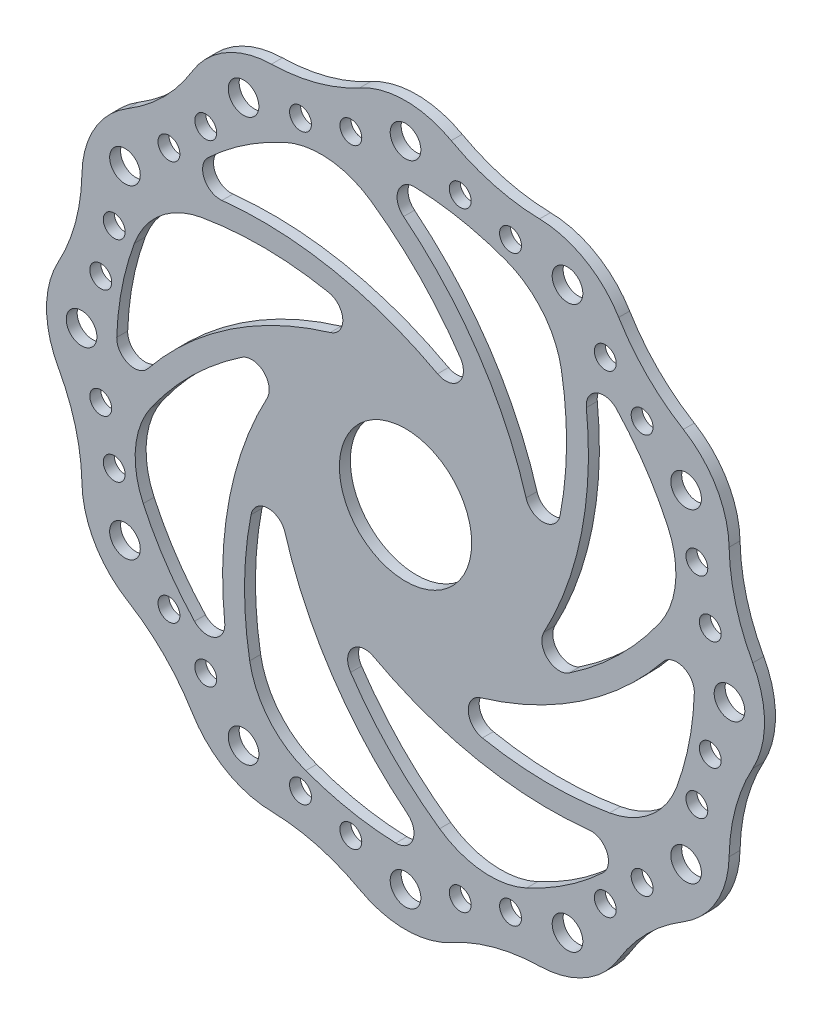
from build123d import *

# Parameters (mm, degrees)
SKETCH1_R           = 3.5
SKETCH1_R_2         = 2.5
BOSS_EXTRUDE1_DEPTH = 2.5
SKETCH2_R           = 15.109152198
CUT_EXTRUDE1_DEPTH  = 5


with BuildPart() as part:
    # Sketch1 → Boss-Extrude1 (new body)
    with BuildSketch(Plane.XY):
        with BuildLine():
            ThreePointArc((3625.909665863, 499.953549868), (3625.227827051, 505.34436193), (3623.225254773, 510.395645245))
            ThreePointArc((3623.225254773, 510.395645245), (3620.967241243, 515.156207087), (3619.298998646, 520.154060705))
            ThreePointArc((3619.298998646, 520.154060705), (3618.244812306, 525.316450201), (3617.820028464, 530.568224457))
            ThreePointArc((3617.820028464, 530.568224457), (3617.028665272, 535.944050269), (3614.923748973, 540.953549868))
            ThreePointArc((3614.923748973, 540.953549868), (3611.63785321, 545.281210655), (3607.377933086, 548.654464189))
            ThreePointArc((3607.377933086, 548.654464189), (3603.042155087, 551.648224915), (3599.098487809, 555.142371814))
            ThreePointArc((3599.098487809, 555.142371814), (3595.60434091, 559.086039091), (3592.610580184, 563.421817091))
            ThreePointArc((3592.610580184, 563.421817091), (3589.23732665, 567.681737215), (3584.909665863, 570.967632978))
            ThreePointArc((3584.909665863, 570.967632978), (3579.900166264, 573.072549277), (3574.524340452, 573.863912469))
            ThreePointArc((3574.524340452, 573.863912469), (3569.272566196, 574.288696311), (3564.1101767, 575.342882651))
            ThreePointArc((3564.1101767, 575.342882651), (3559.112323082, 577.011125248), (3554.35176124, 579.269138778))
            ThreePointArc((3554.35176124, 579.269138778), (3549.300477925, 581.271711056), (3543.909665863, 581.953549868))
            ThreePointArc((3543.909665863, 581.953549868), (3538.5188538, 581.271711056), (3533.467570485, 579.269138778))
            ThreePointArc((3533.467570485, 579.269138778), (3528.707008644, 577.011125248), (3523.709155026, 575.342882651))
            ThreePointArc((3523.709155026, 575.342882651), (3518.54676553, 574.288696311), (3513.294991274, 573.863912469))
            ThreePointArc((3513.294991274, 573.863912469), (3507.919165462, 573.072549277), (3502.909665863, 570.967632978))
            ThreePointArc((3502.909665863, 570.967632978), (3498.582005075, 567.681737215), (3495.208751542, 563.421817091))
            ThreePointArc((3495.208751542, 563.421817091), (3492.214990816, 559.086039091), (3488.720843917, 555.142371814))
            ThreePointArc((3488.720843917, 555.142371814), (3484.777176639, 551.648224915), (3480.44139864, 548.654464189))
            ThreePointArc((3480.44139864, 548.654464189), (3476.181478516, 545.281210655), (3472.895582753, 540.953549868))
            ThreePointArc((3472.895582753, 540.953549868), (3470.790666453, 535.944050269), (3469.999303262, 530.568224457))
            ThreePointArc((3469.999303262, 530.568224457), (3469.57451942, 525.316450201), (3468.520333079, 520.154060705))
            ThreePointArc((3468.520333079, 520.154060705), (3466.852090483, 515.156207087), (3464.594076953, 510.395645245))
            ThreePointArc((3464.594076953, 510.395645245), (3462.591504675, 505.34436193), (3461.909665863, 499.953549868))
            ThreePointArc((3461.909665863, 499.953549868), (3462.591504675, 494.562737805), (3464.594076953, 489.51145449))
            ThreePointArc((3464.594076953, 489.51145449), (3466.852090483, 484.750892649), (3468.520333079, 479.753039031))
            ThreePointArc((3468.520333079, 479.753039031), (3469.57451942, 474.590649535), (3469.999303262, 469.338875279))
            ThreePointArc((3469.999303262, 469.338875279), (3470.790666453, 463.963049467), (3472.895582753, 458.953549868))
            ThreePointArc((3472.895582753, 458.953549868), (3476.181478516, 454.62588908), (3480.44139864, 451.252635547))
            ThreePointArc((3480.44139864, 451.252635547), (3484.777176639, 448.258874821), (3488.720843917, 444.764727922))
            ThreePointArc((3488.720843917, 444.764727922), (3492.214990816, 440.821060644), (3495.208751542, 436.485282645))
            ThreePointArc((3495.208751542, 436.485282645), (3498.582005075, 432.225362521), (3502.909665863, 428.939466758))
            ThreePointArc((3502.909665863, 428.939466758), (3507.919165462, 426.834550458), (3513.294991274, 426.043187267))
            ThreePointArc((3513.294991274, 426.043187267), (3518.54676553, 425.618403425), (3523.709155026, 424.564217084))
            ThreePointArc((3523.709155026, 424.564217084), (3528.707008644, 422.895974488), (3533.467570485, 420.637960958))
            ThreePointArc((3533.467570485, 420.637960958), (3538.5188538, 418.63538868), (3543.909665863, 417.953549868))
            ThreePointArc((3543.909665863, 417.953549868), (3549.300477925, 418.63538868), (3554.35176124, 420.637960958))
            ThreePointArc((3554.35176124, 420.637960958), (3559.112323082, 422.895974488), (3564.1101767, 424.564217084))
            ThreePointArc((3564.1101767, 424.564217084), (3569.272566196, 425.618403425), (3574.524340452, 426.043187267))
            ThreePointArc((3574.524340452, 426.043187267), (3579.900166264, 426.834550458), (3584.909665863, 428.939466758))
            ThreePointArc((3584.909665863, 428.939466758), (3589.23732665, 432.225362521), (3592.610580184, 436.485282645))
            ThreePointArc((3592.610580184, 436.485282645), (3595.60434091, 440.821060644), (3599.098487809, 444.764727922))
            ThreePointArc((3599.098487809, 444.764727922), (3603.042155087, 448.258874821), (3607.377933086, 451.252635547))
            ThreePointArc((3607.377933086, 451.252635547), (3611.63785321, 454.62588908), (3614.923748973, 458.953549868))
            ThreePointArc((3614.923748973, 458.953549868), (3617.028665272, 463.963049467), (3617.820028464, 469.338875279))
            ThreePointArc((3617.820028464, 469.338875279), (3618.244812306, 474.590649535), (3619.298998646, 479.753039031))
            ThreePointArc((3619.298998646, 479.753039031), (3620.967241243, 484.750892649), (3623.225254773, 489.51145449))
            ThreePointArc((3623.225254773, 489.51145449), (3625.227827051, 494.562737805), (3625.909665863, 499.953549868))
        make_face()
        with Locations((3617.909665863, 499.953549868)):
            Circle(SKETCH1_R, mode=Mode.SUBTRACT)
        with Locations((3607.995545743, 536.953549868)):
            Circle(SKETCH1_R, mode=Mode.SUBTRACT)
        with Locations((3610.447392765, 523.939428905)):
            Circle(SKETCH1_R_2, mode=Mode.SUBTRACT)
        with Locations((3613.525967189, 512.45003274)):
            Circle(SKETCH1_R_2, mode=Mode.SUBTRACT)
        with Locations((3589.540088151, 553.994793897)):
            Circle(SKETCH1_R_2, mode=Mode.SUBTRACT)
        with Locations((3597.950909892, 545.583972156)):
            Circle(SKETCH1_R_2, mode=Mode.SUBTRACT)
        with Locations((3580.909665863, 564.039429748)):
            Circle(SKETCH1_R, mode=Mode.SUBTRACT)
        with Locations((3556.406148735, 569.569851194)):
            Circle(SKETCH1_R_2, mode=Mode.SUBTRACT)
        with Locations((3567.8955449, 566.49127677)):
            Circle(SKETCH1_R_2, mode=Mode.SUBTRACT)
        with Locations((3543.909665863, 573.953549868)):
            Circle(SKETCH1_R, mode=Mode.SUBTRACT)
        with Locations((3519.923786825, 566.49127677)):
            Circle(SKETCH1_R_2, mode=Mode.SUBTRACT)
        with Locations((3531.413182991, 569.569851194)):
            Circle(SKETCH1_R_2, mode=Mode.SUBTRACT)
        with Locations((3506.909665863, 564.039429748)):
            Circle(SKETCH1_R, mode=Mode.SUBTRACT)
        with Locations((3489.868421833, 545.583972156)):
            Circle(SKETCH1_R_2, mode=Mode.SUBTRACT)
        with Locations((3498.279243575, 553.994793897)):
            Circle(SKETCH1_R_2, mode=Mode.SUBTRACT)
        with Locations((3479.823785983, 536.953549868)):
            Circle(SKETCH1_R, mode=Mode.SUBTRACT)
        with Locations((3474.293364537, 512.45003274)):
            Circle(SKETCH1_R_2, mode=Mode.SUBTRACT)
        with Locations((3477.371938961, 523.939428905)):
            Circle(SKETCH1_R_2, mode=Mode.SUBTRACT)
        with Locations((3469.909665863, 499.953549868)):
            Circle(SKETCH1_R, mode=Mode.SUBTRACT)
        with Locations((3477.371938961, 475.96767083)):
            Circle(SKETCH1_R_2, mode=Mode.SUBTRACT)
        with Locations((3474.293364537, 487.457066996)):
            Circle(SKETCH1_R_2, mode=Mode.SUBTRACT)
        with Locations((3479.823785983, 462.953549868)):
            Circle(SKETCH1_R, mode=Mode.SUBTRACT)
        with Locations((3498.279243575, 445.912305838)):
            Circle(SKETCH1_R_2, mode=Mode.SUBTRACT)
        with Locations((3489.868421833, 454.32312758)):
            Circle(SKETCH1_R_2, mode=Mode.SUBTRACT)
        with Locations((3506.909665863, 435.867669988)):
            Circle(SKETCH1_R, mode=Mode.SUBTRACT)
        with Locations((3531.413182991, 430.337248542)):
            Circle(SKETCH1_R_2, mode=Mode.SUBTRACT)
        with Locations((3519.923786825, 433.415822966)):
            Circle(SKETCH1_R_2, mode=Mode.SUBTRACT)
        with Locations((3543.909665863, 425.953549868)):
            Circle(SKETCH1_R, mode=Mode.SUBTRACT)
        with Locations((3567.8955449, 433.415822966)):
            Circle(SKETCH1_R_2, mode=Mode.SUBTRACT)
        with Locations((3556.406148735, 430.337248542)):
            Circle(SKETCH1_R_2, mode=Mode.SUBTRACT)
        with Locations((3580.909665863, 435.867669988)):
            Circle(SKETCH1_R, mode=Mode.SUBTRACT)
        with Locations((3597.950909892, 454.32312758)):
            Circle(SKETCH1_R_2, mode=Mode.SUBTRACT)
        with Locations((3589.540088151, 445.912305838)):
            Circle(SKETCH1_R_2, mode=Mode.SUBTRACT)
        with Locations((3607.995545743, 462.953549868)):
            Circle(SKETCH1_R, mode=Mode.SUBTRACT)
        with Locations((3613.525967189, 487.457066996)):
            Circle(SKETCH1_R_2, mode=Mode.SUBTRACT)
        with Locations((3610.447392765, 475.96767083)):
            Circle(SKETCH1_R_2, mode=Mode.SUBTRACT)
        with BuildLine():
            ThreePointArc((3566.713860053, 561.888747674), (3556.573793938, 564.727154524), (3546.111375484, 565.916815969))
            ThreePointArc((3546.111375484, 565.916815969), (3542.228665981, 563.312941578), (3543.467367871, 558.805036015))
            ThreePointArc((3543.467367871, 558.805036015), (3560.615566984, 540.092276254), (3571.445948255, 517.137299622))
            ThreePointArc((3571.445948255, 517.137299622), (3575.471641714, 514.287171209), (3579.203655705, 517.512308627))
            ThreePointArc((3579.203655705, 517.512308627), (3580.689955133, 532.024170682), (3579.504873824, 546.563730805))
            ThreePointArc((3579.504873824, 546.563730805), (3575.15798218, 555.936114406), (3566.713860053, 561.888747674))
        make_face(mode=Mode.SUBTRACT)
        with BuildLine():
            ThreePointArc((3516.239867851, 559.873348582), (3507.062701609, 554.710295802), (3498.823436897, 548.153466441))
            ThreePointArc((3498.823436897, 548.153466441), (3497.919163917, 543.566758982), (3501.982629016, 541.255082896))
            ThreePointArc((3501.982629016, 541.255082896), (3527.340156215, 540.148771452), (3551.230011893, 531.575387854))
            ThreePointArc((3551.230011893, 531.575387854), (3556.091952166, 532.406637869), (3556.450368028, 537.326086808))
            ThreePointArc((3556.450368028, 537.326086808), (3547.239904365, 548.638495279), (3536.120903777, 558.081537808))
            ThreePointArc((3536.120903777, 558.081537808), (3526.419911218, 561.63509725), (3516.239867851, 559.873348582))
        make_face(mode=Mode.SUBTRACT)
        with BuildLine():
            ThreePointArc((3481.974468056, 522.757744058), (3479.136061207, 512.617677943), (3477.946399762, 502.155259489))
            ThreePointArc((3477.946399762, 502.155259489), (3480.550274153, 498.272549986), (3485.058179715, 499.511251876))
            ThreePointArc((3485.058179715, 499.511251876), (3503.770939476, 516.659450988), (3526.725916108, 527.48983226))
            ThreePointArc((3526.725916108, 527.48983226), (3529.576044522, 531.515525719), (3526.350907104, 535.24753971))
            ThreePointArc((3526.350907104, 535.24753971), (3511.839045049, 536.733839138), (3497.299484926, 535.548757829))
            ThreePointArc((3497.299484926, 535.548757829), (3487.927101325, 531.201866185), (3481.974468056, 522.757744058))
        make_face(mode=Mode.SUBTRACT)
        with BuildLine():
            ThreePointArc((3483.989867148, 472.283751856), (3489.152919929, 463.106585614), (3495.70974929, 454.867320902))
            ThreePointArc((3495.70974929, 454.867320902), (3500.296456749, 453.963047922), (3502.608132834, 458.026513021))
            ThreePointArc((3502.608132834, 458.026513021), (3503.714444278, 483.38404022), (3512.287827877, 507.273895898))
            ThreePointArc((3512.287827877, 507.273895898), (3511.456577862, 512.135836171), (3506.537128922, 512.494252033))
            ThreePointArc((3506.537128922, 512.494252033), (3495.224720452, 503.28378837), (3485.781677923, 492.164787782))
            ThreePointArc((3485.781677923, 492.164787782), (3482.228118481, 482.463795223), (3483.989867148, 472.283751856))
        make_face(mode=Mode.SUBTRACT)
        with BuildLine():
            ThreePointArc((3521.105471673, 438.018352061), (3531.245537787, 435.179945212), (3541.707956241, 433.990283767))
            ThreePointArc((3541.707956241, 433.990283767), (3545.590665745, 436.594158158), (3544.351963855, 441.10206372))
            ThreePointArc((3544.351963855, 441.10206372), (3527.203764742, 459.814823481), (3516.373383471, 482.769800113))
            ThreePointArc((3516.373383471, 482.769800113), (3512.347690012, 485.619928527), (3508.61567602, 482.394791109))
            ThreePointArc((3508.61567602, 482.394791109), (3507.129376593, 467.882929054), (3508.314457902, 453.343368931))
            ThreePointArc((3508.314457902, 453.343368931), (3512.661349545, 443.97098533), (3521.105471673, 438.018352061))
        make_face(mode=Mode.SUBTRACT)
        with BuildLine():
            ThreePointArc((3571.579463875, 440.033751153), (3580.756630117, 445.196803934), (3588.995894829, 451.753633295))
            ThreePointArc((3588.995894829, 451.753633295), (3589.900167809, 456.340340754), (3585.83670271, 458.652016839))
            ThreePointArc((3585.83670271, 458.652016839), (3560.479175511, 459.758328283), (3536.589319832, 468.331711882))
            ThreePointArc((3536.589319832, 468.331711882), (3531.72737956, 467.500461867), (3531.368963698, 462.581012927))
            ThreePointArc((3531.368963698, 462.581012927), (3540.57942736, 451.268604457), (3551.698427949, 441.825561928))
            ThreePointArc((3551.698427949, 441.825561928), (3561.399420507, 438.272002486), (3571.579463875, 440.033751153))
        make_face(mode=Mode.SUBTRACT)
        with BuildLine():
            ThreePointArc((3605.844863669, 477.149355678), (3608.683270519, 487.289421792), (3609.872931964, 497.751840246))
            ThreePointArc((3609.872931964, 497.751840246), (3607.269057573, 501.63454975), (3602.76115201, 500.39584786))
            ThreePointArc((3602.76115201, 500.39584786), (3584.04839225, 483.247648747), (3561.093415617, 472.417267476))
            ThreePointArc((3561.093415617, 472.417267476), (3558.243287204, 468.391574017), (3561.468424622, 464.659560025))
            ThreePointArc((3561.468424622, 464.659560025), (3575.980286677, 463.173260598), (3590.5198468, 464.358341907))
            ThreePointArc((3590.5198468, 464.358341907), (3599.892230401, 468.70523355), (3605.844863669, 477.149355678))
        make_face(mode=Mode.SUBTRACT)
        with BuildLine():
            ThreePointArc((3603.829464577, 527.62334788), (3598.666411797, 536.800514122), (3592.109582436, 545.039778834))
            ThreePointArc((3592.109582436, 545.039778834), (3587.522874977, 545.944051814), (3585.211198892, 541.880586715))
            ThreePointArc((3585.211198892, 541.880586715), (3584.104887447, 516.523059516), (3575.531503849, 492.633203837))
            ThreePointArc((3575.531503849, 492.633203837), (3576.362753864, 487.771263565), (3581.282202803, 487.412847703))
            ThreePointArc((3581.282202803, 487.412847703), (3592.594611274, 496.623311365), (3602.037653803, 507.742311954))
            ThreePointArc((3602.037653803, 507.742311954), (3605.591213245, 517.443304512), (3603.829464577, 527.62334788))
        make_face(mode=Mode.SUBTRACT)
    extrude(amount=BOSS_EXTRUDE1_DEPTH)

    # Sketch2 → Cut-Extrude1 (cut, symmetric)
    with BuildSketch(Plane(origin=(0, 0, 0), x_dir=(-1, 0, 0), z_dir=(0, 0, -1))):
        with Locations((-3543.909665863, 501.971759943)):
            Circle(SKETCH2_R)
    extrude(amount=CUT_EXTRUDE1_DEPTH, both=True, mode=Mode.SUBTRACT)


solid = part.part
